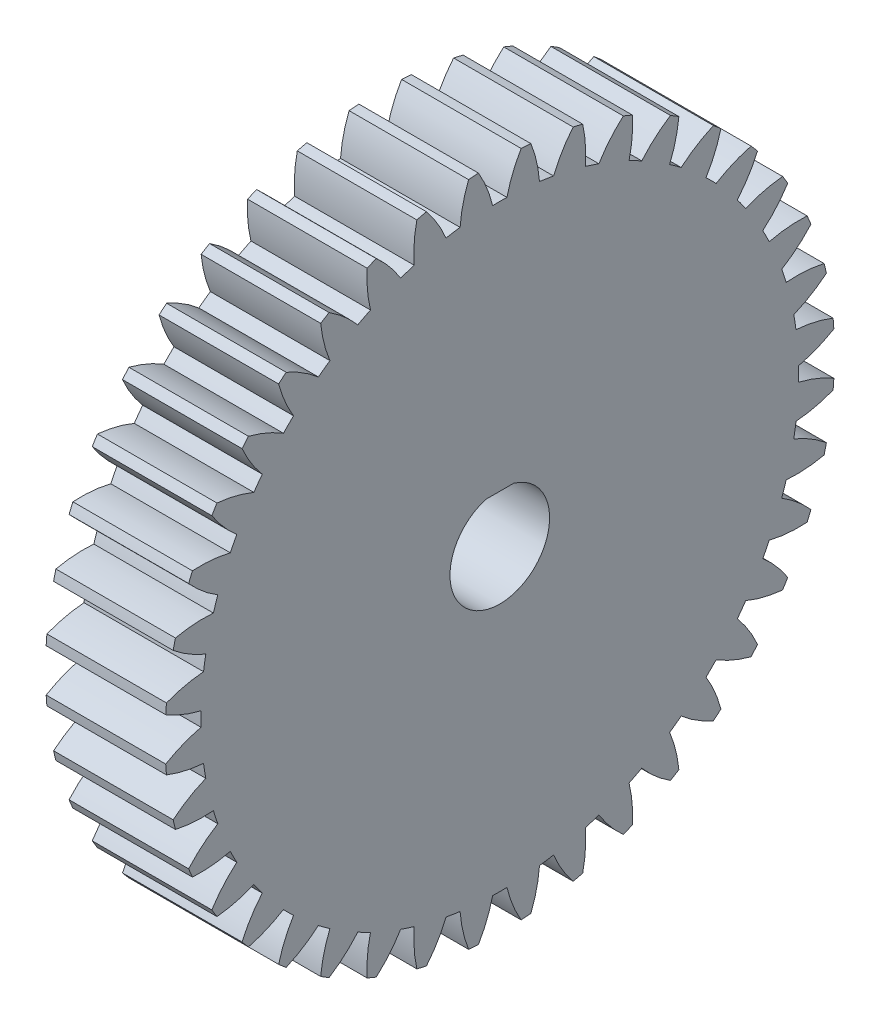
from build123d import *

# Parameters (mm, degrees)
SKETCH1_R           = 2.5
BOSS_EXTRUDE1_DEPTH = 6
BOSS_EXTRUDE2_DEPTH = 6


with BuildPart() as part:
    # Sketch1 → Boss-Extrude1 (new body)
    with BuildSketch(Plane(origin=(6, 0, 0), x_dir=(0, 0, -1), z_dir=(1, 0, 0))):
        with BuildLine():
            ThreePointArc((2.699515676, 14.754071171), (2.346360541, 14.814337421), (1.991866754, 14.866151749))
            ThreePointArc((1.991866754, 14.866151749), (1.847959654, 15.812600658), (1.564486987, 16.72699556))
            ThreePointArc((1.564486987, 16.72699556), (1.318112808, 16.748211207), (1.071453046, 16.765798173))
            ThreePointArc((1.071453046, 16.765798173), (0.648427521, 15.907005884), (0.358234928, 14.994721362))
            ThreePointArc((0.358234928, 14.994721362), (0, 14.999), (-0.358234928, 14.994721362))
            ThreePointArc((-0.358234928, 14.994721362), (-0.648427521, 15.907005884), (-1.071453046, 16.765798173))
            ThreePointArc((-1.071453046, 16.765798173), (-1.318112808, 16.748211207), (-1.564486987, 16.72699556))
            ThreePointArc((-1.564486987, 16.72699556), (-1.847959654, 15.812600658), (-1.991866754, 14.866151749))
            ThreePointArc((-1.991866754, 14.866151749), (-2.346360541, 14.814337421), (-2.699515676, 14.754071171))
            ThreePointArc((-2.699515676, 14.754071171), (-3.128848258, 15.609727833), (-3.68101035, 16.391771192))
            ThreePointArc((-3.68101035, 16.391771192), (-3.921882113, 16.335814663), (-4.161904158, 16.276318803))
            ThreePointArc((-4.161904158, 16.276318803), (-4.298843929, 15.328836725), (-4.292922065, 14.371528142))
            ThreePointArc((-4.292922065, 14.371528142), (-4.634945899, 14.264896688), (-4.974325389, 14.150126781))
            ThreePointArc((-4.974325389, 14.150126781), (-5.532226367, 14.928086477), (-6.199928961, 15.614124403))
            ThreePointArc((-6.199928961, 15.614124403), (-6.429081664, 15.521176146), (-6.656841436, 15.424865059))
            ThreePointArc((-6.656841436, 15.424865059), (-6.643876399, 14.467625957), (-6.488271387, 13.523029816))
            ThreePointArc((-6.488271387, 13.523029816), (-6.809403506, 13.364206856), (-7.126650702, 13.197759308))
            ThreePointArc((-7.126650702, 13.197759308), (-7.799382702, 13.878866089), (-8.566184746, 14.452006051))
            ThreePointArc((-8.566184746, 14.452006051), (-8.777975887, 14.324354761), (-8.987865186, 14.193599945))
            ThreePointArc((-8.987865186, 14.193599945), (-8.825314583, 13.250174224), (-8.523857935, 12.341549615))
            ThreePointArc((-8.523857935, 12.341549615), (-8.816190999, 12.134445899), (-9.103494223, 11.920419201))
            ThreePointArc((-9.103494223, 11.920419201), (-9.874492351, 12.487901956), (-10.721512632, 12.934031347))
            ThreePointArc((-10.721512632, 12.934031347), (-10.910727212, 12.774820222), (-11.097577865, 12.612841295))
            ThreePointArc((-11.097577865, 12.612841295), (-10.789444232, 11.706459226), (-10.349558811, 10.856179504))
            ThreePointArc((-10.349558811, 10.856179504), (-10.605894611, 10.605894611), (-10.856179504, 10.349558811))
            ThreePointArc((-10.856179504, 10.349558811), (-11.706459226, 10.789444232), (-12.612841295, 11.097577865))
            ThreePointArc((-12.612841295, 11.097577865), (-12.774820222, 10.910727212), (-12.934031347, 10.721512632))
            ThreePointArc((-12.934031347, 10.721512632), (-12.487901956, 9.874492351), (-11.920419201, 9.103494223))
            ThreePointArc((-11.920419201, 9.103494223), (-12.134445899, 8.816190999), (-12.341549615, 8.523857935))
            ThreePointArc((-12.341549615, 8.523857935), (-13.250174224, 8.825314583), (-14.193599945, 8.987865186))
            ThreePointArc((-14.193599945, 8.987865186), (-14.324354761, 8.777975887), (-14.452006051, 8.566184746))
            ThreePointArc((-14.452006051, 8.566184746), (-13.878866089, 7.799382702), (-13.197759308, 7.126650702))
            ThreePointArc((-13.197759308, 7.126650702), (-13.364206856, 6.809403506), (-13.523029816, 6.488271387))
            ThreePointArc((-13.523029816, 6.488271387), (-14.467625957, 6.643876399), (-15.424865059, 6.656841436))
            ThreePointArc((-15.424865059, 6.656841436), (-15.521176146, 6.429081664), (-15.614124403, 6.199928961))
            ThreePointArc((-15.614124403, 6.199928961), (-14.928086477, 5.532226367), (-14.150126781, 4.974325389))
            ThreePointArc((-14.150126781, 4.974325389), (-14.264896688, 4.634945899), (-14.371528142, 4.292922065))
            ThreePointArc((-14.371528142, 4.292922065), (-15.328836725, 4.298843929), (-16.276318803, 4.161904158))
            ThreePointArc((-16.276318803, 4.161904158), (-16.335814663, 3.921882113), (-16.391771192, 3.68101035))
            ThreePointArc((-16.391771192, 3.68101035), (-15.609727833, 3.128848258), (-14.754071171, 2.699515676))
            ThreePointArc((-14.754071171, 2.699515676), (-14.814337421, 2.346360541), (-14.866151749, 1.991866754))
            ThreePointArc((-14.866151749, 1.991866754), (-15.812600658, 1.847959654), (-16.72699556, 1.564486987))
            ThreePointArc((-16.72699556, 1.564486987), (-16.748211207, 1.318112808), (-16.765798173, 1.071453046))
            ThreePointArc((-16.765798173, 1.071453046), (-15.907005884, 0.648427521), (-14.994721362, 0.358234928))
            ThreePointArc((-14.994721362, 0.358234928), (-14.999, 0), (-14.994721362, -0.358234928))
            ThreePointArc((-14.994721362, -0.358234928), (-15.907005884, -0.648427521), (-16.765798173, -1.071453046))
            ThreePointArc((-16.765798173, -1.071453046), (-16.748211207, -1.318112808), (-16.72699556, -1.564486987))
            ThreePointArc((-16.72699556, -1.564486987), (-15.812600658, -1.847959654), (-14.866151749, -1.991866754))
            ThreePointArc((-14.866151749, -1.991866754), (-14.814337421, -2.346360541), (-14.754071171, -2.699515676))
            ThreePointArc((-14.754071171, -2.699515676), (-15.609727833, -3.128848258), (-16.391771192, -3.68101035))
            ThreePointArc((-16.391771192, -3.68101035), (-16.335814663, -3.921882113), (-16.276318803, -4.161904158))
            ThreePointArc((-16.276318803, -4.161904158), (-15.328836725, -4.298843929), (-14.371528142, -4.292922065))
            ThreePointArc((-14.371528142, -4.292922065), (-14.264896688, -4.634945899), (-14.150126781, -4.974325389))
            ThreePointArc((-14.150126781, -4.974325389), (-14.928086477, -5.532226367), (-15.614124403, -6.199928961))
            ThreePointArc((-15.614124403, -6.199928961), (-15.521176146, -6.429081664), (-15.424865059, -6.656841436))
            ThreePointArc((-15.424865059, -6.656841436), (-14.467625957, -6.643876399), (-13.523029816, -6.488271387))
            ThreePointArc((-13.523029816, -6.488271387), (-13.364206856, -6.809403506), (-13.197759308, -7.126650702))
            ThreePointArc((-13.197759308, -7.126650702), (-13.878866089, -7.799382702), (-14.452006051, -8.566184746))
            ThreePointArc((-14.452006051, -8.566184746), (-14.324354761, -8.777975887), (-14.193599945, -8.987865186))
            ThreePointArc((-14.193599945, -8.987865186), (-13.250174224, -8.825314583), (-12.341549615, -8.523857935))
            ThreePointArc((-12.341549615, -8.523857935), (-12.134445899, -8.816190999), (-11.920419201, -9.103494223))
            ThreePointArc((-11.920419201, -9.103494223), (-12.487901956, -9.874492351), (-12.934031347, -10.721512632))
            ThreePointArc((-12.934031347, -10.721512632), (-12.774820222, -10.910727212), (-12.612841295, -11.097577865))
            ThreePointArc((-12.612841295, -11.097577865), (-11.706459226, -10.789444232), (-10.856179504, -10.349558811))
            ThreePointArc((-10.856179504, -10.349558811), (-10.605894611, -10.605894611), (-10.349558811, -10.856179504))
            ThreePointArc((-10.349558811, -10.856179504), (-10.789444232, -11.706459226), (-11.097577865, -12.612841295))
            ThreePointArc((-11.097577865, -12.612841295), (-10.910727212, -12.774820222), (-10.721512632, -12.934031347))
            ThreePointArc((-10.721512632, -12.934031347), (-9.874492351, -12.487901956), (-9.103494223, -11.920419201))
            ThreePointArc((-9.103494223, -11.920419201), (-8.816190999, -12.134445899), (-8.523857935, -12.341549615))
            ThreePointArc((-8.523857935, -12.341549615), (-8.825314583, -13.250174224), (-8.987865186, -14.193599945))
            ThreePointArc((-8.987865186, -14.193599945), (-8.777975887, -14.324354761), (-8.566184746, -14.452006051))
            ThreePointArc((-8.566184746, -14.452006051), (-7.799382702, -13.878866089), (-7.126650702, -13.197759308))
            ThreePointArc((-7.126650702, -13.197759308), (-6.809403506, -13.364206856), (-6.488271387, -13.523029816))
            ThreePointArc((-6.488271387, -13.523029816), (-6.643876399, -14.467625957), (-6.656841436, -15.424865059))
            ThreePointArc((-6.656841436, -15.424865059), (-6.429081664, -15.521176146), (-6.199928961, -15.614124403))
            ThreePointArc((-6.199928961, -15.614124403), (-5.532226367, -14.928086477), (-4.974325389, -14.150126781))
            ThreePointArc((-4.974325389, -14.150126781), (-4.634945899, -14.264896688), (-4.292922065, -14.371528142))
            ThreePointArc((-4.292922065, -14.371528142), (-4.298843929, -15.328836725), (-4.161904158, -16.276318803))
            ThreePointArc((-4.161904158, -16.276318803), (-3.921882113, -16.335814663), (-3.68101035, -16.391771192))
            ThreePointArc((-3.68101035, -16.391771192), (-3.128848258, -15.609727833), (-2.699515676, -14.754071171))
            ThreePointArc((-2.699515676, -14.754071171), (-2.346360541, -14.814337421), (-1.991866754, -14.866151749))
            ThreePointArc((-1.991866754, -14.866151749), (-1.847959654, -15.812600658), (-1.564486987, -16.72699556))
            ThreePointArc((-1.564486987, -16.72699556), (-1.318112808, -16.748211207), (-1.071453046, -16.765798173))
            ThreePointArc((-1.071453046, -16.765798173), (-0.648427521, -15.907005884), (-0.358234928, -14.994721362))
            ThreePointArc((-0.358234928, -14.994721362), (0, -14.999), (0.358234928, -14.994721362))
            ThreePointArc((0.358234928, -14.994721362), (0.648427521, -15.907005884), (1.071453046, -16.765798173))
            ThreePointArc((1.071453046, -16.765798173), (1.318112808, -16.748211207), (1.564486987, -16.72699556))
            ThreePointArc((1.564486987, -16.72699556), (1.847959654, -15.812600658), (1.991866754, -14.866151749))
            ThreePointArc((1.991866754, -14.866151749), (2.346360541, -14.814337421), (2.699515676, -14.754071171))
            ThreePointArc((2.699515676, -14.754071171), (3.128848258, -15.609727833), (3.68101035, -16.391771192))
            ThreePointArc((3.68101035, -16.391771192), (3.921882113, -16.335814663), (4.161904158, -16.276318803))
            ThreePointArc((4.161904158, -16.276318803), (4.298843929, -15.328836725), (4.292922065, -14.371528142))
            ThreePointArc((4.292922065, -14.371528142), (4.634945899, -14.264896688), (4.974325389, -14.150126781))
            ThreePointArc((4.974325389, -14.150126781), (5.532226367, -14.928086477), (6.199928961, -15.614124403))
            ThreePointArc((6.199928961, -15.614124403), (6.429081664, -15.521176146), (6.656841436, -15.424865059))
            ThreePointArc((6.656841436, -15.424865059), (6.643876399, -14.467625957), (6.488271387, -13.523029816))
            ThreePointArc((6.488271387, -13.523029816), (6.809403506, -13.364206856), (7.126650702, -13.197759308))
            ThreePointArc((7.126650702, -13.197759308), (7.799382702, -13.878866089), (8.566184746, -14.452006051))
            ThreePointArc((8.566184746, -14.452006051), (8.777975887, -14.324354761), (8.987865186, -14.193599945))
            ThreePointArc((8.987865186, -14.193599945), (8.825314583, -13.250174224), (8.523857935, -12.341549615))
            ThreePointArc((8.523857935, -12.341549615), (8.816190999, -12.134445899), (9.103494223, -11.920419201))
            ThreePointArc((9.103494223, -11.920419201), (9.874492351, -12.487901956), (10.721512632, -12.934031347))
            ThreePointArc((10.721512632, -12.934031347), (10.910727212, -12.774820222), (11.097577865, -12.612841295))
            ThreePointArc((11.097577865, -12.612841295), (10.789444232, -11.706459226), (10.349558811, -10.856179504))
            ThreePointArc((10.349558811, -10.856179504), (10.605894611, -10.605894611), (10.856179504, -10.349558811))
            ThreePointArc((10.856179504, -10.349558811), (11.706459226, -10.789444232), (12.612841295, -11.097577865))
            ThreePointArc((12.612841295, -11.097577865), (12.774820222, -10.910727212), (12.934031347, -10.721512632))
            ThreePointArc((12.934031347, -10.721512632), (12.487901956, -9.874492351), (11.920419201, -9.103494223))
            ThreePointArc((11.920419201, -9.103494223), (12.134445899, -8.816190999), (12.341549615, -8.523857935))
            ThreePointArc((12.341549615, -8.523857935), (13.250174224, -8.825314583), (14.193599945, -8.987865186))
            ThreePointArc((14.193599945, -8.987865186), (14.324354761, -8.777975887), (14.452006051, -8.566184746))
            ThreePointArc((14.452006051, -8.566184746), (13.878866089, -7.799382702), (13.197759308, -7.126650702))
            ThreePointArc((13.197759308, -7.126650702), (13.364206856, -6.809403506), (13.523029816, -6.488271387))
            ThreePointArc((13.523029816, -6.488271387), (14.467625957, -6.643876399), (15.424865059, -6.656841436))
            ThreePointArc((15.424865059, -6.656841436), (15.521176146, -6.429081664), (15.614124403, -6.199928961))
            ThreePointArc((15.614124403, -6.199928961), (14.928086477, -5.532226367), (14.150126781, -4.974325389))
            ThreePointArc((14.150126781, -4.974325389), (14.264896688, -4.634945899), (14.371528142, -4.292922065))
            ThreePointArc((14.371528142, -4.292922065), (15.328836725, -4.298843929), (16.276318803, -4.161904158))
            ThreePointArc((16.276318803, -4.161904158), (16.335814663, -3.921882113), (16.391771192, -3.68101035))
            ThreePointArc((16.391771192, -3.68101035), (15.609727833, -3.128848258), (14.754071171, -2.699515676))
            ThreePointArc((14.754071171, -2.699515676), (14.814337421, -2.346360541), (14.866151749, -1.991866754))
            ThreePointArc((14.866151749, -1.991866754), (15.812600658, -1.847959654), (16.72699556, -1.564486987))
            ThreePointArc((16.72699556, -1.564486987), (16.748211207, -1.318112808), (16.765798173, -1.071453046))
            ThreePointArc((16.765798173, -1.071453046), (15.907005884, -0.648427521), (14.994721362, -0.358234928))
            ThreePointArc((14.994721362, -0.358234928), (14.999, 0), (14.994721362, 0.358234928))
            ThreePointArc((14.994721362, 0.358234928), (15.907005884, 0.648427521), (16.765798173, 1.071453046))
            ThreePointArc((16.765798173, 1.071453046), (16.748211207, 1.318112808), (16.72699556, 1.564486987))
            ThreePointArc((16.72699556, 1.564486987), (15.812600658, 1.847959654), (14.866151749, 1.991866754))
            ThreePointArc((14.866151749, 1.991866754), (14.814337421, 2.346360541), (14.754071171, 2.699515676))
            ThreePointArc((14.754071171, 2.699515676), (15.609727833, 3.128848258), (16.391771192, 3.68101035))
            ThreePointArc((16.391771192, 3.68101035), (16.335814663, 3.921882113), (16.276318803, 4.161904158))
            ThreePointArc((16.276318803, 4.161904158), (15.328836725, 4.298843929), (14.371528142, 4.292922065))
            ThreePointArc((14.371528142, 4.292922065), (14.264896688, 4.634945899), (14.150126781, 4.974325389))
            ThreePointArc((14.150126781, 4.974325389), (14.928086477, 5.532226367), (15.614124403, 6.199928961))
            ThreePointArc((15.614124403, 6.199928961), (15.521176146, 6.429081664), (15.424865059, 6.656841436))
            ThreePointArc((15.424865059, 6.656841436), (14.467625957, 6.643876399), (13.523029816, 6.488271387))
            ThreePointArc((13.523029816, 6.488271387), (13.364206856, 6.809403506), (13.197759308, 7.126650702))
            ThreePointArc((13.197759308, 7.126650702), (13.878866089, 7.799382702), (14.452006051, 8.566184746))
            ThreePointArc((14.452006051, 8.566184746), (14.324354761, 8.777975887), (14.193599945, 8.987865186))
            ThreePointArc((14.193599945, 8.987865186), (13.250174224, 8.825314583), (12.341549615, 8.523857935))
            ThreePointArc((12.341549615, 8.523857935), (12.134445899, 8.816190999), (11.920419201, 9.103494223))
            ThreePointArc((11.920419201, 9.103494223), (12.487901956, 9.874492351), (12.934031347, 10.721512632))
            ThreePointArc((12.934031347, 10.721512632), (12.774820222, 10.910727212), (12.612841295, 11.097577865))
            ThreePointArc((12.612841295, 11.097577865), (11.706459226, 10.789444232), (10.856179504, 10.349558811))
            ThreePointArc((10.856179504, 10.349558811), (10.605894611, 10.605894611), (10.349558811, 10.856179504))
            ThreePointArc((10.349558811, 10.856179504), (10.789444232, 11.706459226), (11.097577865, 12.612841295))
            ThreePointArc((11.097577865, 12.612841295), (10.910727212, 12.774820222), (10.721512632, 12.934031347))
            ThreePointArc((10.721512632, 12.934031347), (9.874492351, 12.487901956), (9.103494223, 11.920419201))
            ThreePointArc((9.103494223, 11.920419201), (8.816190999, 12.134445899), (8.523857935, 12.341549615))
            ThreePointArc((8.523857935, 12.341549615), (8.825314583, 13.250174224), (8.987865186, 14.193599945))
            ThreePointArc((8.987865186, 14.193599945), (8.777975887, 14.324354761), (8.566184746, 14.452006051))
            ThreePointArc((8.566184746, 14.452006051), (7.799382702, 13.878866089), (7.126650702, 13.197759308))
            ThreePointArc((7.126650702, 13.197759308), (6.809403506, 13.364206856), (6.488271387, 13.523029816))
            ThreePointArc((6.488271387, 13.523029816), (6.643876399, 14.467625957), (6.656841436, 15.424865059))
            ThreePointArc((6.656841436, 15.424865059), (6.429081664, 15.521176146), (6.199928961, 15.614124403))
            ThreePointArc((6.199928961, 15.614124403), (5.532226367, 14.928086477), (4.974325389, 14.150126781))
            ThreePointArc((4.974325389, 14.150126781), (4.634945899, 14.264896688), (4.292922065, 14.371528142))
            ThreePointArc((4.292922065, 14.371528142), (4.298843929, 15.328836725), (4.161904158, 16.276318803))
            ThreePointArc((4.161904158, 16.276318803), (3.921882113, 16.335814663), (3.68101035, 16.391771192))
            ThreePointArc((3.68101035, 16.391771192), (3.128848258, 15.609727833), (2.699515676, 14.754071171))
        make_face()
        Circle(SKETCH1_R, mode=Mode.SUBTRACT)
    extrude(amount=-BOSS_EXTRUDE1_DEPTH)

    # Sketch2 → Boss-Extrude2 (add)
    with BuildSketch(Plane(origin=(6, 0, 0), x_dir=(0, 0, -1), z_dir=(1, 0, 0))):
        with BuildLine():
            Line((-0.7, 2.4), (0.7, 2.4))
            ThreePointArc((0.7, 2.4), (0, 2.5), (-0.7, 2.4))
        make_face()
    extrude(amount=-BOSS_EXTRUDE2_DEPTH)


solid = part.part
